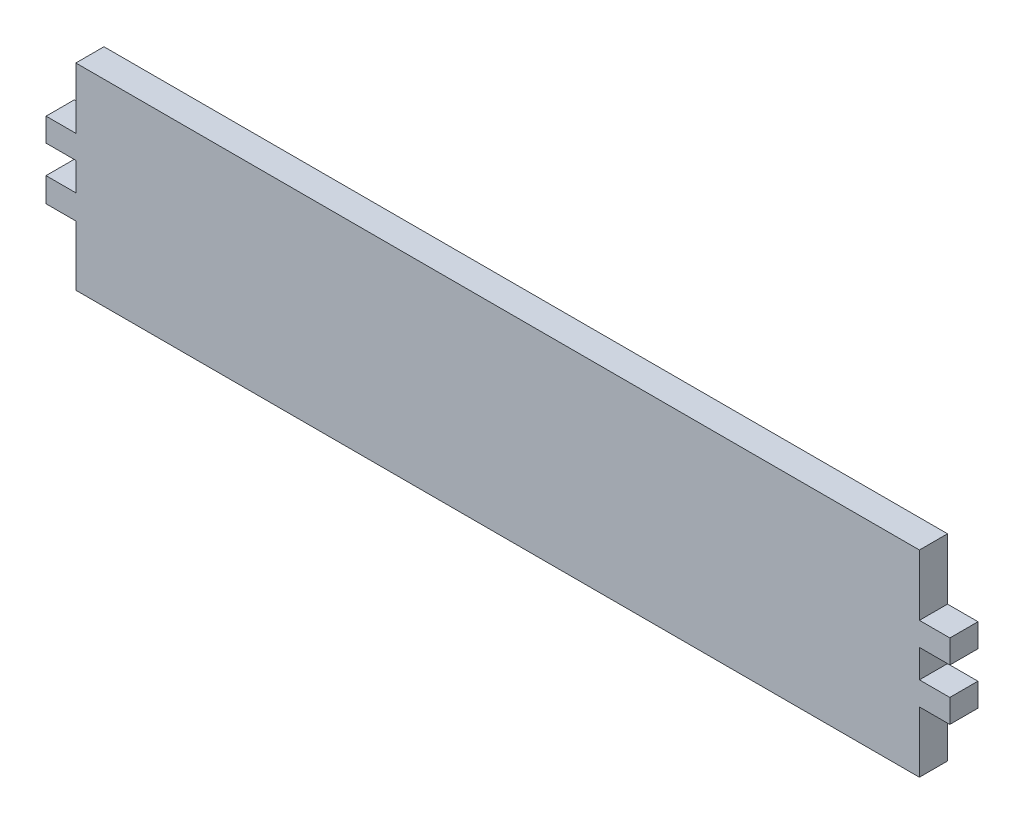
from build123d import *

# Parameters (mm, degrees)
BOSS_EXTRUDE1_DEPTH = 6


with BuildPart() as part:
    # Sketch3 → Boss-Extrude1 (new body)
    with BuildSketch(Plane.XY):
        Polygon((-59.917123056, 29.20445586), (120.082876944, 29.20445586), (120.082876944, 16.20445586), (126.58490102, 16.20445586), (126.58490102, 11.20445586), (120.082876944, 11.20445586), (120.082876944, 5.20445586), (126.566559382, 5.20445586), (126.566559382, 0.20445586), (120.082876944, 0.20445586), (120.082876944, -12.79554414), (-59.917123056, -12.79554414), (-59.917123056, 0), (-66.28611421, 0), (-66.28611421, 5.20445586), (-59.917123056, 5.20445586), (-59.917123056, 11.20445586), (-66.268401935, 11.20445586), (-66.268401935, 16.20445586), (-59.917123056, 16.20445586), align=None)
    extrude(amount=BOSS_EXTRUDE1_DEPTH)


solid = part.part
